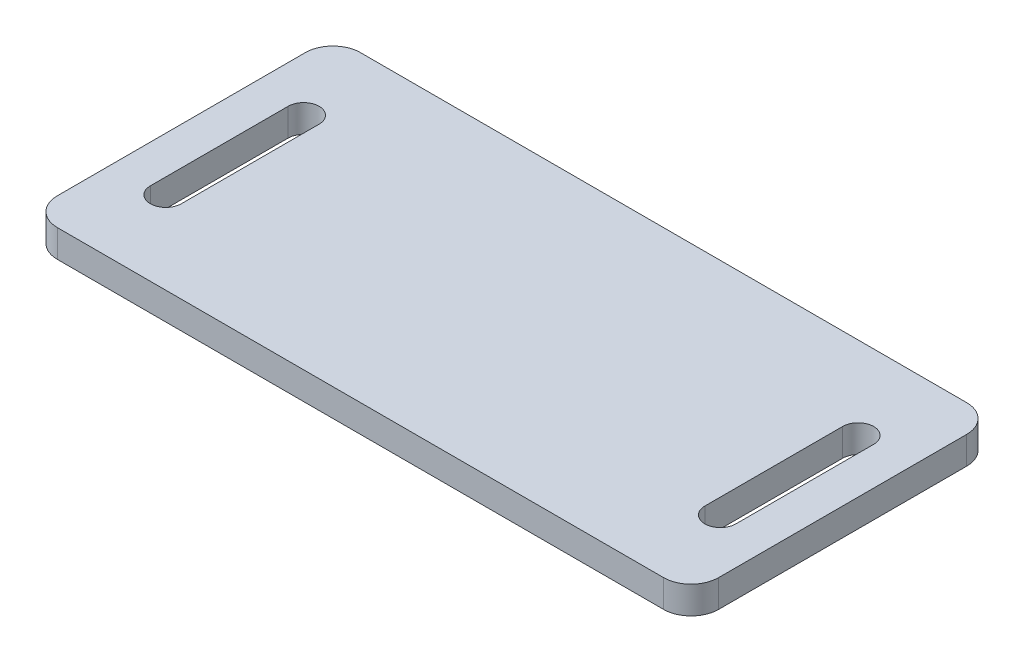
from build123d import *

# Parameters (mm, degrees)
BOSS_EXTRUDE1_DEPTH = 2


with BuildPart() as part:
    # Sketch1 → Boss-Extrude1 (new body, symmetric)
    with BuildSketch(Plane(origin=(0, 0, 0), x_dir=(1, 0, 0), z_dir=(0, 1, 0))):
        with BuildLine():
            Line((-44, -22), (44, -22))
            ThreePointArc((44, -22), (46.828427125, -20.828427125), (48, -18))
            Line((48, -18), (48, 18))
            ThreePointArc((48, 18), (46.828427125, 20.828427125), (44, 22))
            Line((44, 22), (-44, 22))
            ThreePointArc((-44, 22), (-46.828427125, 20.828427125), (-48, 18))
            Line((-48, 18), (-48, -18))
            ThreePointArc((-48, -18), (-46.828427125, -20.828427125), (-44, -22))
        make_face()
        with BuildLine():
            Line((-38, 10), (-38, -10))
            ThreePointArc((-38, -10), (-40.25, -12.25), (-42.5, -10))
            Line((-42.5, -10), (-42.5, 10))
            ThreePointArc((-42.5, 10), (-40.25, 12.25), (-38, 10))
        make_face(mode=Mode.SUBTRACT)
        with BuildLine():
            Line((42.5, 10), (42.5, -10))
            ThreePointArc((42.5, -10), (40.25, -12.25), (38, -10))
            Line((38, -10), (38, 10))
            ThreePointArc((38, 10), (40.25, 12.25), (42.5, 10))
        make_face(mode=Mode.SUBTRACT)
    extrude(amount=BOSS_EXTRUDE1_DEPTH, both=True)


solid = part.part
